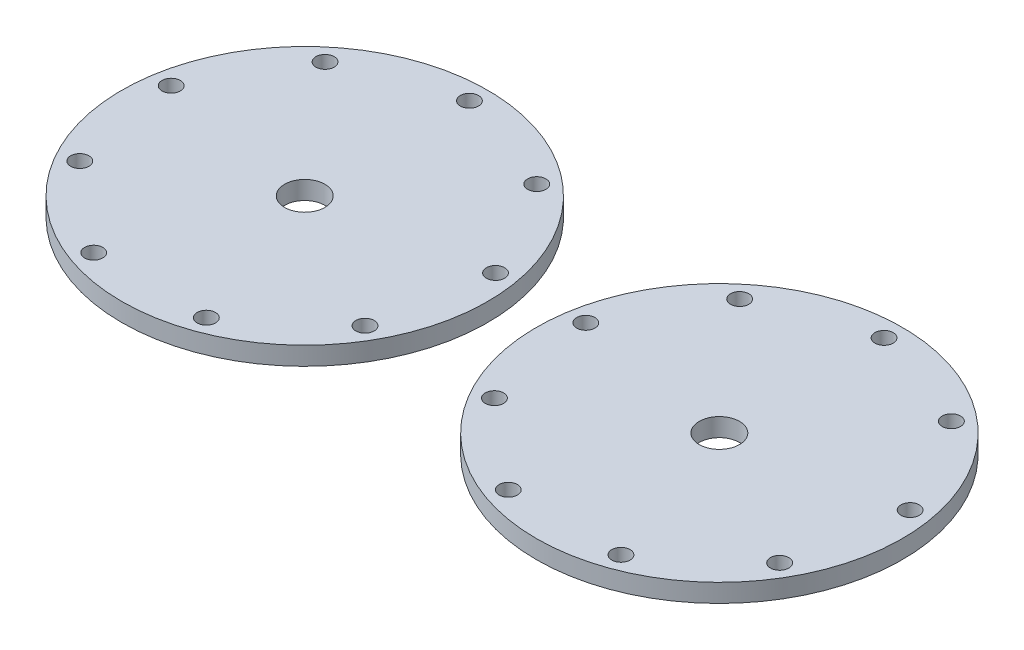
from build123d import *

# Parameters (mm, degrees)
SKETCH_1_R        = 60
SKETCH_1_R_2      = 3
SKETCH_1_R_3      = 6.6
EXTRUDE_1_DEPTH   = 6
EXTRUDE_1_2_DEPTH = 6


with BuildPart() as part:
    # 草图1 → 凸台-拉伸1 (new body)
    with BuildSketch(Plane(origin=(0, 0, 0), x_dir=(1, 0, 0), z_dir=(0, 1, 0))):
        Circle(SKETCH_1_R)
        with Locations((0, 54)):
            Circle(SKETCH_1_R_2, mode=Mode.SUBTRACT)
        Circle(SKETCH_1_R_3, mode=Mode.SUBTRACT)
        with Locations((34.710530923, 41.366399928)):
            Circle(SKETCH_1_R_2, mode=Mode.SUBTRACT)
        with Locations((53.179618663, 9.377001594)):
            Circle(SKETCH_1_R_2, mode=Mode.SUBTRACT)
        with Locations((46.765371804, -27)):
            Circle(SKETCH_1_R_2, mode=Mode.SUBTRACT)
        with Locations((18.46908774, -50.743401522)):
            Circle(SKETCH_1_R_2, mode=Mode.SUBTRACT)
        with Locations((-18.46908774, -50.743401522)):
            Circle(SKETCH_1_R_2, mode=Mode.SUBTRACT)
        with Locations((-46.765371804, -27)):
            Circle(SKETCH_1_R_2, mode=Mode.SUBTRACT)
        with Locations((-53.179618663, 9.377001594)):
            Circle(SKETCH_1_R_2, mode=Mode.SUBTRACT)
        with Locations((-34.710530923, 41.366399928)):
            Circle(SKETCH_1_R_2, mode=Mode.SUBTRACT)
    extrude(amount=EXTRUDE_1_DEPTH)


with BuildPart() as body_2:
    # 草图1 → Extrude 1 2 (new body)
    with BuildSketch(Plane(origin=(0, 0, 0), x_dir=(1, 0, 0), z_dir=(0, 1, 0))):
        with Locations((-135.319032656, -0.643151296)):
            Circle(SKETCH_1_R)
        with Locations((-135.319032656, 53.356848704)):
            Circle(SKETCH_1_R_2, mode=Mode.SUBTRACT)
        with Locations((-135.319032656, -0.643151296)):
            Circle(SKETCH_1_R_3, mode=Mode.SUBTRACT)
        with Locations((-100.608501733, 40.723248633)):
            Circle(SKETCH_1_R_2, mode=Mode.SUBTRACT)
        with Locations((-82.139413994, 8.733850298)):
            Circle(SKETCH_1_R_2, mode=Mode.SUBTRACT)
        with Locations((-88.553660852, -27.643151296)):
            Circle(SKETCH_1_R_2, mode=Mode.SUBTRACT)
        with Locations((-116.849944917, -51.386552818)):
            Circle(SKETCH_1_R_2, mode=Mode.SUBTRACT)
        with Locations((-153.788120396, -51.386552818)):
            Circle(SKETCH_1_R_2, mode=Mode.SUBTRACT)
        with Locations((-182.084404461, -27.643151296)):
            Circle(SKETCH_1_R_2, mode=Mode.SUBTRACT)
        with Locations((-188.498651319, 8.733850298)):
            Circle(SKETCH_1_R_2, mode=Mode.SUBTRACT)
        with Locations((-170.02956358, 40.723248633)):
            Circle(SKETCH_1_R_2, mode=Mode.SUBTRACT)
    extrude(amount=EXTRUDE_1_2_DEPTH)


solid = Compound([part.part, body_2.part])
